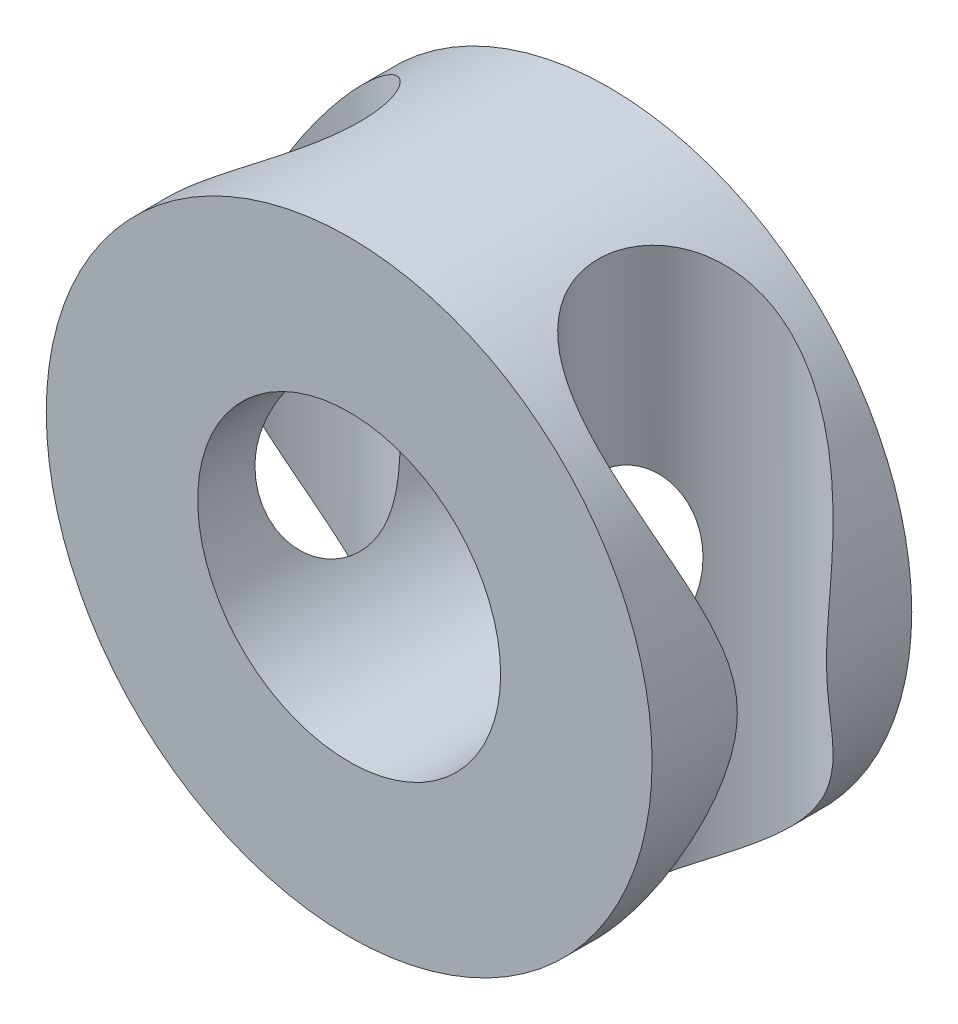
from build123d import *

# Parameters (mm, degrees)
ESQUISSE1_R      = 7
ESQUISSE1_R_2    = 3.5
EXTRUSION1_DEPTH = 6
ESQUISSE3_R      = 2.25
EXTRUSION4_DEPTH = 15


with BuildPart() as part:
    # Esquisse1 → Extrusion1 (new body)
    with BuildSketch(Plane.XY):
        Circle(ESQUISSE1_R)
        Circle(ESQUISSE1_R_2, mode=Mode.SUBTRACT)
    extrude(amount=EXTRUSION1_DEPTH)

    # Esquisse3 → Extrusion4 (cut, through all)
    with BuildSketch(Plane(origin=(0, 7, 0), x_dir=(-1, 0, 0), z_dir=(0, 1, 0))):
        with Locations((5, 3)):
            Circle(ESQUISSE3_R)
        with Locations((-5, 3)):
            Circle(ESQUISSE3_R)
    extrude(amount=-EXTRUSION4_DEPTH, mode=Mode.SUBTRACT)


solid = part.part
